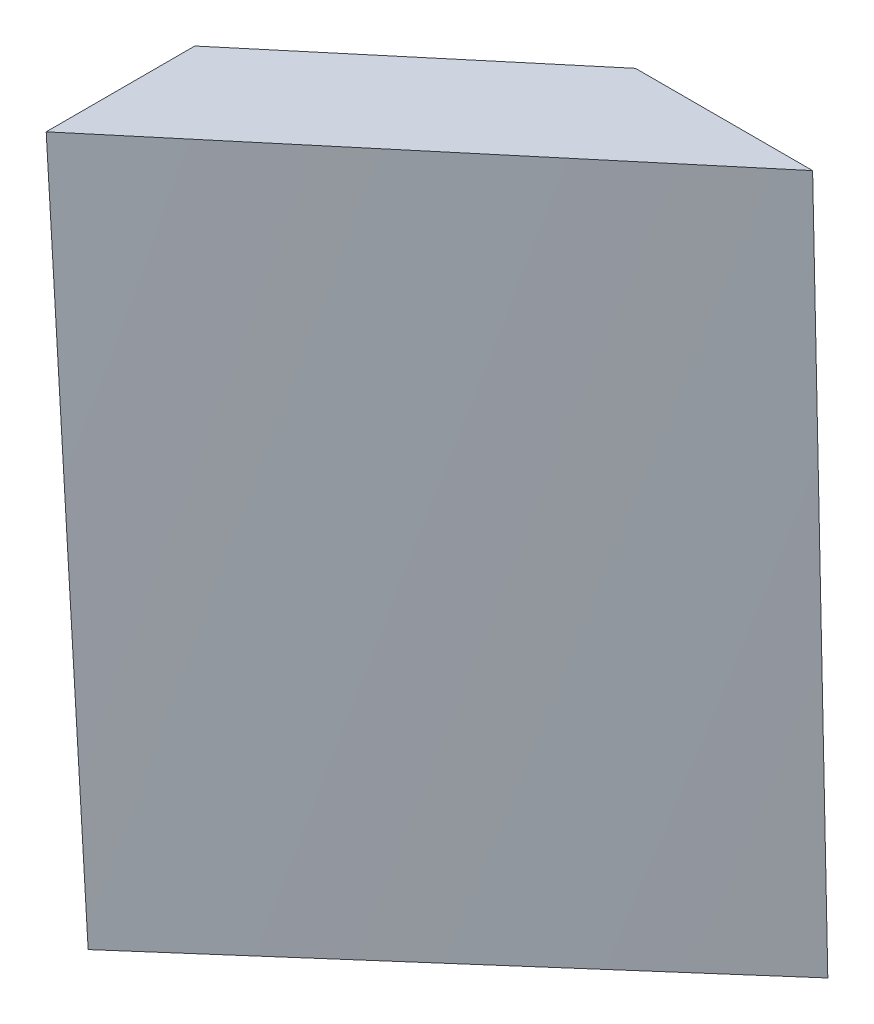
from build123d import *


with BuildPart() as part:
    # Croquis2 → Recubrir1 section 0
    with BuildSketch(Plane(origin=(0, 75, 0), x_dir=(1, 0, 0), z_dir=(0, 1, 0))):
        Polygon((40.693880572, 38.858804133), (21.243694938, 38.858804133), (-5.075639943, 16.785854366), (-5.075639943, 0.465854366), align=None)
    # Croquis1 → Recubrir1 section 1
    with BuildSketch(Plane(origin=(0, 0, 0), x_dir=(1, 0, 0), z_dir=(0, 1, 0))):
        Polygon((0, 0), (0, 16.32), (23.863694938, 37.908804133), (43.313694938, 37.908804133), align=None)
    loft()


solid = part.part
